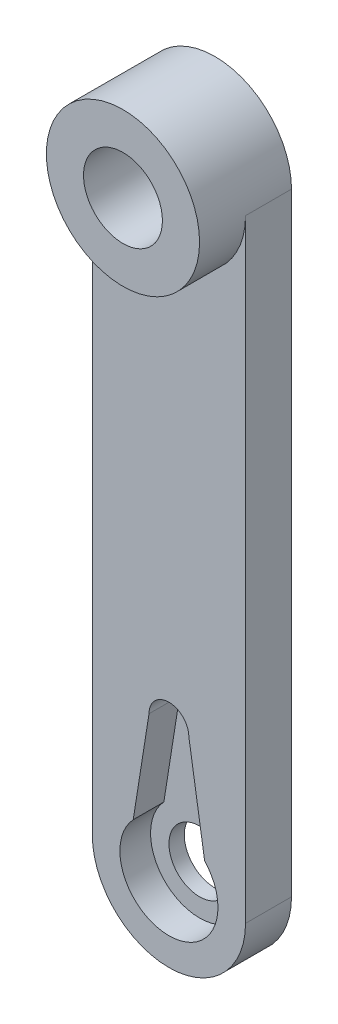
from build123d import *

# Parameters (mm, degrees)
SKETCH_1_R          = 4
EXTRUDE_1_DEPTH     = 6
SKETCH_1_3_R        = 5.15
EXTRUDE_2_DEPTH     = 12
CUT_EXTRUDE_1_DEPTH = 4


with BuildPart() as part:
    # Эскиз1 → Бобышка-Вытянуть1 (new body)
    with BuildSketch(Plane.XY):
        with BuildLine():
            ThreePointArc((-10, 0), (0, -10), (10, 0))
            Line((10, 0), (10, 80))
            ThreePointArc((10, 80), (0, 70), (-10, 80))
            Line((-10, 80), (-10, 0))
        make_face()
        Circle(SKETCH_1_R, mode=Mode.SUBTRACT)
    extrude(amount=EXTRUDE_1_DEPTH)

    # Эскиз1<3> → Бобышка-Вытянуть2 (add)
    with BuildSketch(Plane.XY):
        with BuildLine():
            ThreePointArc((10, 80), (0, 90), (-10, 80))
            ThreePointArc((-10, 80), (0, 70), (10, 80))
        make_face()
        with Locations((0, 80)):
            Circle(SKETCH_1_3_R, mode=Mode.SUBTRACT)
    extrude(amount=EXTRUDE_2_DEPTH)

    # Эскиз2 → Вырез-Вытянуть1 (cut)
    with BuildSketch(Plane.XY.offset(6)):
        with BuildLine():
            Line((4.661300265, 4.385462329), (2.6, 17.4))
            ThreePointArc((2.6, 17.4), (0, 20), (-2.6, 17.4))
            Line((-2.6, 17.4), (-4.661300265, 4.385462329))
            ThreePointArc((-4.661300265, 4.385462329), (0, -6.4), (4.661300265, 4.385462329))
        make_face()
    extrude(amount=-CUT_EXTRUDE_1_DEPTH, mode=Mode.SUBTRACT)


solid = part.part
